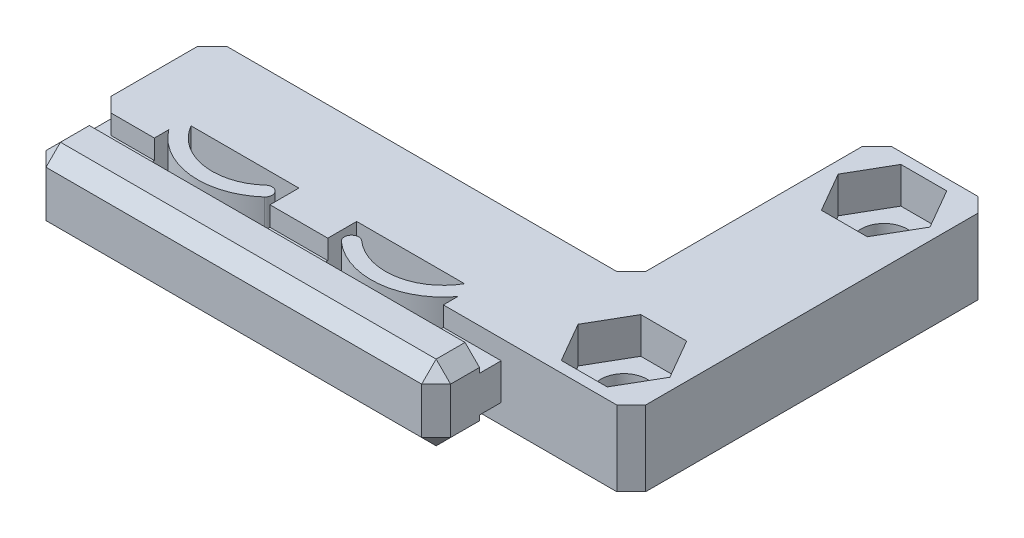
from build123d import *

# Parameters (mm, degrees)
BOSS_EXTRUDE1_DEPTH = 2.6
BOSS_EXTRUDE2_DEPTH = 4
BOSS_EXTRUDE3_DEPTH = 4
SKETCH4_W           = 3
SKETCH4_H           = 5.2
BOSS_EXTRUDE4_DEPTH = 8
BOSS_EXTRUDE5_DEPTH = 2.6
SKETCH6_R           = 1.6
CUT_EXTRUDE1_DEPTH  = 6.2
CUT_EXTRUDE2_DEPTH  = 2.5
CHAMFER1_SIZE       = 1


with BuildPart() as part:
    # Sketch1 → Boss-Extrude1 (new body, symmetric)
    with BuildSketch(Plane(origin=(0, 0, 0), x_dir=(1, 0, 0), z_dir=(0, 1, 0))):
        Polygon((0, 0), (0, 25), (-8, 25), (-8, 8), (-37, 8), (-37, 0), (-33, 0), (-33, 2), (-25, 2), (-25, 0), (-21, 0), (-21, 2), (-13, 2), (-13, 0), align=None)
    extrude(amount=BOSS_EXTRUDE1_DEPTH, both=True)

    # Sketch2 → Boss-Extrude2 (add)
    with BuildSketch(Plane.ZY.offset(13)):
        Polygon((1.5, -1.25), (1.5, -2.6), (4.5, -2.6), (4.5, 2.6), (1.5, 2.6), (1.5, 1.25), (0, 1.25), (0, -1.25), align=None)
    boss_extrude2 = extrude(amount=-BOSS_EXTRUDE2_DEPTH)

    # Sketch3 → Boss-Extrude3 (add)
    with BuildSketch(Plane.ZY.offset(25)):
        Polygon((0, 1.25), (0, -1.25), (1.5, -1.25), (1.5, -2.6), (4.5, -2.6), (4.5, 2.6), (1.5, 2.6), (1.5, 1.25), align=None)
    extrude(amount=-BOSS_EXTRUDE3_DEPTH)

    # Sketch4 → Boss-Extrude4 (add)
    with BuildSketch(Plane.ZY.offset(13)):
        with Locations((3, 0)):
            Rectangle(SKETCH4_W, SKETCH4_H)
    boss_extrude4 = extrude(amount=BOSS_EXTRUDE4_DEPTH)

    # Sketch5 → Boss-Extrude5 (add, symmetric)
    with BuildSketch(Plane(origin=(0, 0, 0), x_dir=(1, 0, 0), z_dir=(0, 1, 0))):
        with BuildLine():
            Line((-13, 1), (-13, 2))
            Line((-13, 2), (-13.535898385, 2))
            ThreePointArc((-13.535898385, 2), (-16.36772326, 0.050287843), (-19.666666667, 1.01857603))
            ThreePointArc((-19.666666667, 1.01857603), (-20.372677996, 0.979231367), (-20.333333333, 0.273220038))
            ThreePointArc((-20.333333333, 0.273220038), (-16.506884, -0.975624243), (-13, 1))
        make_face()
    boss_extrude5 = extrude(amount=BOSS_EXTRUDE5_DEPTH, both=True)

    # Mirror1: Boss-Extrude2, Boss-Extrude4, Boss-Extrude5 across plane
    add(boss_extrude2.mirror(Plane.ZY.offset(23)))
    add(boss_extrude4.mirror(Plane.ZY.offset(23)))
    add(boss_extrude5.mirror(Plane.ZY.offset(23)))

    # Sketch6 → Cut-Extrude1 (cut, through all)
    with BuildSketch(Plane(origin=(0, 2.6, 0), x_dir=(1, 0, 0), z_dir=(0, 1, 0))):
        with Locations((-4, 21.5)):
            Circle(SKETCH6_R)
        with Locations((-4, 3.5)):
            Circle(SKETCH6_R)
    extrude(amount=-CUT_EXTRUDE1_DEPTH, mode=Mode.SUBTRACT)

    # Sketch7 → Cut-Extrude2 (cut)
    with BuildSketch(Plane(origin=(0, 2.6, 0), x_dir=(1, 0, 0), z_dir=(0, 1, 0))):
        Polygon((-0.824573519, 3.5), (-2.41228676, 6.25), (-5.58771324, 6.25), (-7.175426481, 3.5), (-5.58771324, 0.75), (-2.41228676, 0.75), align=None)
        Polygon((-0.824573519, 21.5), (-2.41228676, 24.25), (-5.58771324, 24.25), (-7.175426481, 21.5), (-5.58771324, 18.75), (-2.41228676, 18.75), align=None)
    extrude(amount=-CUT_EXTRUDE2_DEPTH, mode=Mode.SUBTRACT)

    # Chamfer1
    chamfer1_edges = [part.edges().sort_by_distance(p)[0] for p in [
        (-9, 0, 4.5),
        (-9, -2.6, 3),
        (-23, -2.6, 4.5),
        (-9, 2.6, 3),
        (-23, 2.6, 4.5),
        (-37, -2.6, 3),
        (-37, 2.6, 3),
        (-37, 0, 4.5),
        (-37, 1.925, 0),
        (-37, -1.925, 0),
        (-37, 0, -8),
        (-8, 0, -8),
        (0, 0, 0),
        (0, 0, -25),
        (-8, 0, -25),
    ]]
    chamfer(chamfer1_edges, length=CHAMFER1_SIZE)


solid = part.part
